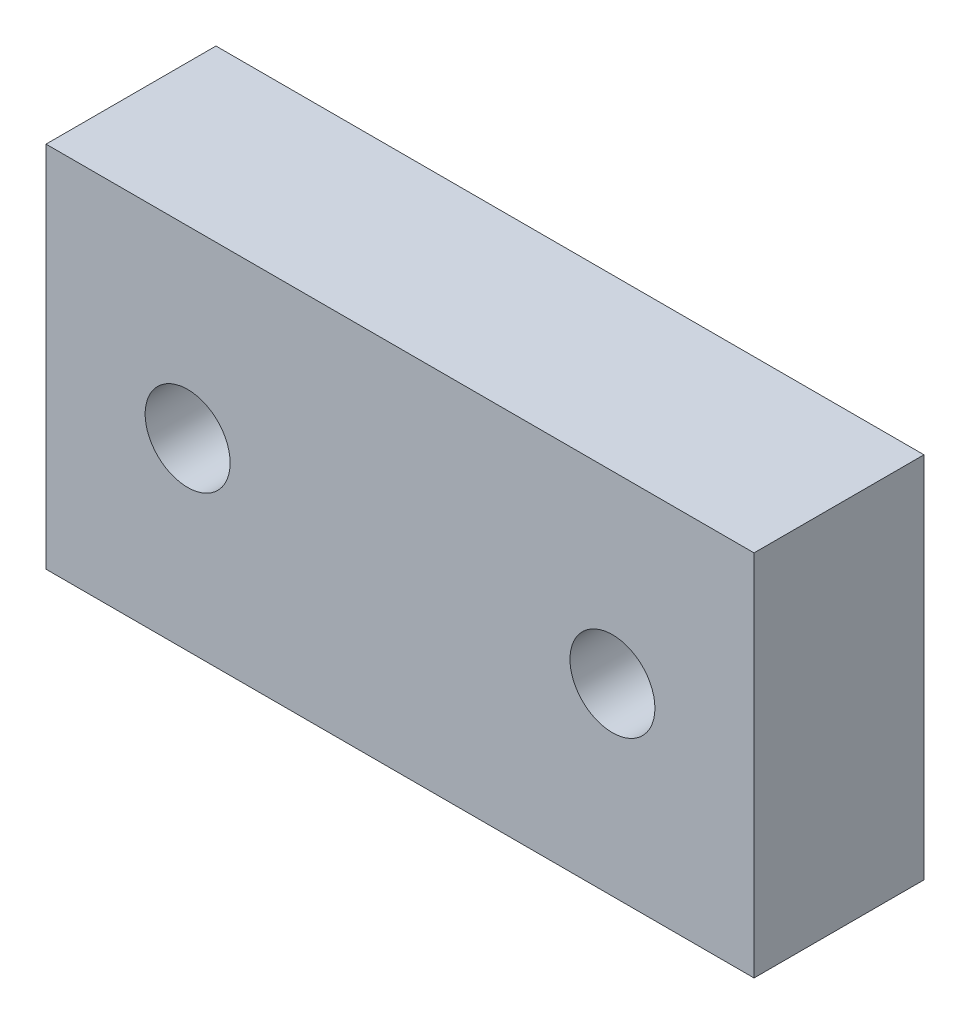
from build123d import *

# Parameters (mm, degrees)
ESBO_O1_W                = 25
ESBO_O1_H                = 13
ESBO_O1_R                = 1.5
RESSALTO_EXTRUS_O1_DEPTH = 6


with BuildPart() as part:
    # Esboço1 → Ressalto-extrusão1 (new body)
    with BuildSketch(Plane.XY):
        with Locations((12.5, 6.5)):
            Rectangle(ESBO_O1_W, ESBO_O1_H)
        with Locations((5, 6.5)):
            Circle(ESBO_O1_R, mode=Mode.SUBTRACT)
        with Locations((20, 6.5)):
            Circle(ESBO_O1_R, mode=Mode.SUBTRACT)
    extrude(amount=RESSALTO_EXTRUS_O1_DEPTH)


solid = part.part
